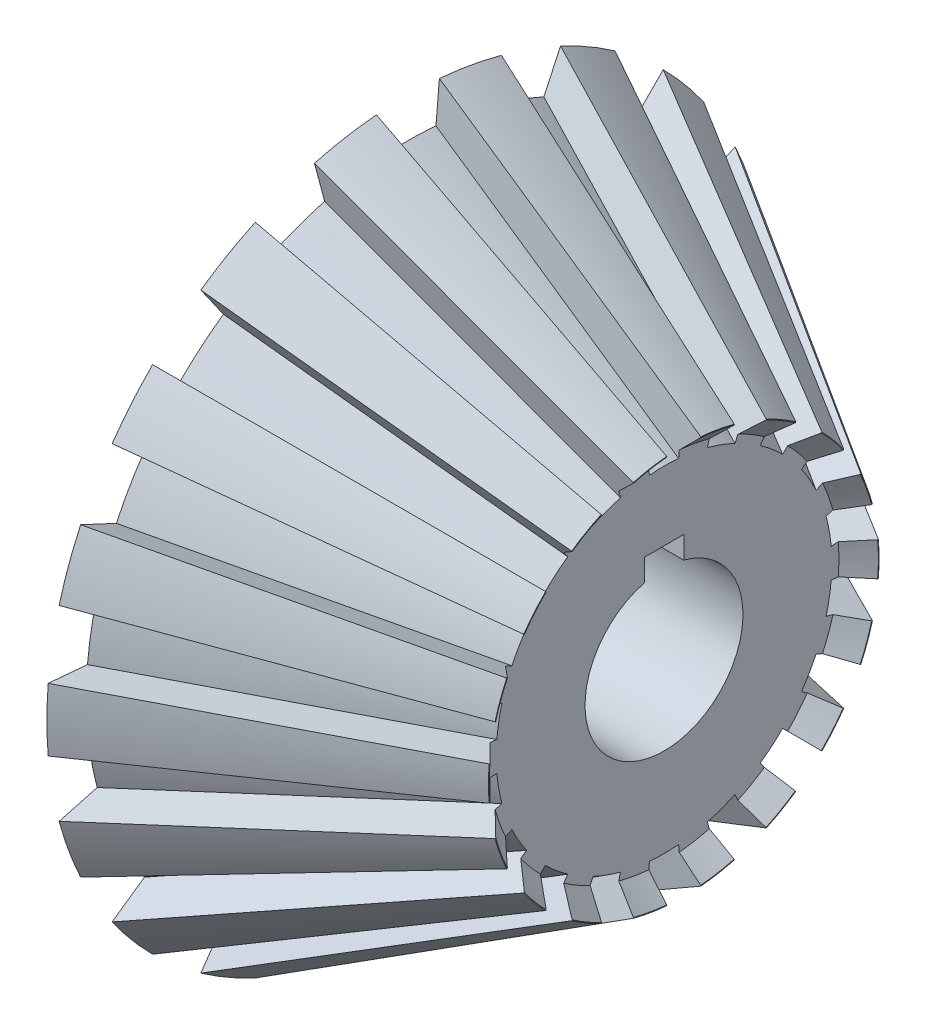
from build123d import *

# Parameters (mm, degrees)
CHANFRO1_SIZE         = 3.96875
CORTE_REVOLU_O1_ANGLE = 10
PADR_OCIRCULAR1_COUNT = 18
ESBO_O8_W             = 10
ESBO_O8_H             = 10
CORTE_EXTRUS_O1_DEPTH = 92.04375


with BuildPart() as part:
    # Esboço1 → Revolução1 (revolve)
    with BuildSketch(Plane.XY):
        Polygon((0, 20), (0, 39.6875), (26.19375, 39.6875), (26.19375, 91.44), (96.04375, 49.469885761), (96.04375, 20), align=None)
    revolve(axis=Axis((206.361590972, 0, 0), (-1, 0, 0)))

    # Chanfro1
    chanfro1_edges = [part.edges().sort_by_distance(p)[0] for p in [
        (0, -39.6875, 0),
    ]]
    chamfer(chanfro1_edges, length=CHANFRO1_SIZE)

    # Esboço3 → Corte-Revolução1 (revolve, symmetric, cut)
    with BuildSketch(Plane.XY) as corte_revolu_o1_sk:
        Polygon((96.04375, 49.469885761), (26.19375, 91.44), (26.19375, 81.455895118), (96.04375, 39.485780879), align=None)
    corte_revolu_o1 = revolve(axis=Axis((96.04375, 0, 0), (1, 0, 0)), revolution_arc=CORTE_REVOLU_O1_ANGLE / 2, mode=Mode.SUBTRACT)
    corte_revolu_o1 = corte_revolu_o1 + revolve(corte_revolu_o1_sk.sketch, axis=Axis((96.04375, 0, 0), (-1, 0, 0)), revolution_arc=CORTE_REVOLU_O1_ANGLE / 2, mode=Mode.SUBTRACT)

    # PadrãoCircular1: Corte-Revolução1 ×18 about axis
    padr_ocircular1_axis = Axis((0, 0, 0), (1, 0, 0))
    for i in range(1, PADR_OCIRCULAR1_COUNT):
        add(corte_revolu_o1.rotate(padr_ocircular1_axis, i * 360 / PADR_OCIRCULAR1_COUNT), mode=Mode.SUBTRACT)

    # Esboço7 → Corte-Revolução2 (revolve, cut)
    with BuildSketch(Plane(origin=(0, 0, 0), x_dir=(1, 0, 0), z_dir=(0, 1, 0)), mode=Mode.PRIVATE) as corte_revolu_o2_sk:
        Polygon((96.04375, 0), (96.04375, 49.28163791), (91.04375, 44.28163791), (91.04375, 0), align=None)
    revolve(corte_revolu_o2_sk.sketch.rotate(Axis((91.04375, 0, 0), (1, 0, 0)), 90), axis=Axis((91.04375, 0, 0), (1, 0, 0)), mode=Mode.SUBTRACT)  # turned: the seam where the file's is

    # Esboço8 → Corte-extrusão1 (cut, through all)
    with BuildSketch(Plane(origin=(91.04375, 0, 0), x_dir=(0, 0, -1), z_dir=(1, 0, 0))):
        with Locations((0, 20)):
            Rectangle(ESBO_O8_W, ESBO_O8_H)
    extrude(amount=-CORTE_EXTRUS_O1_DEPTH, mode=Mode.SUBTRACT)


solid = part.part
